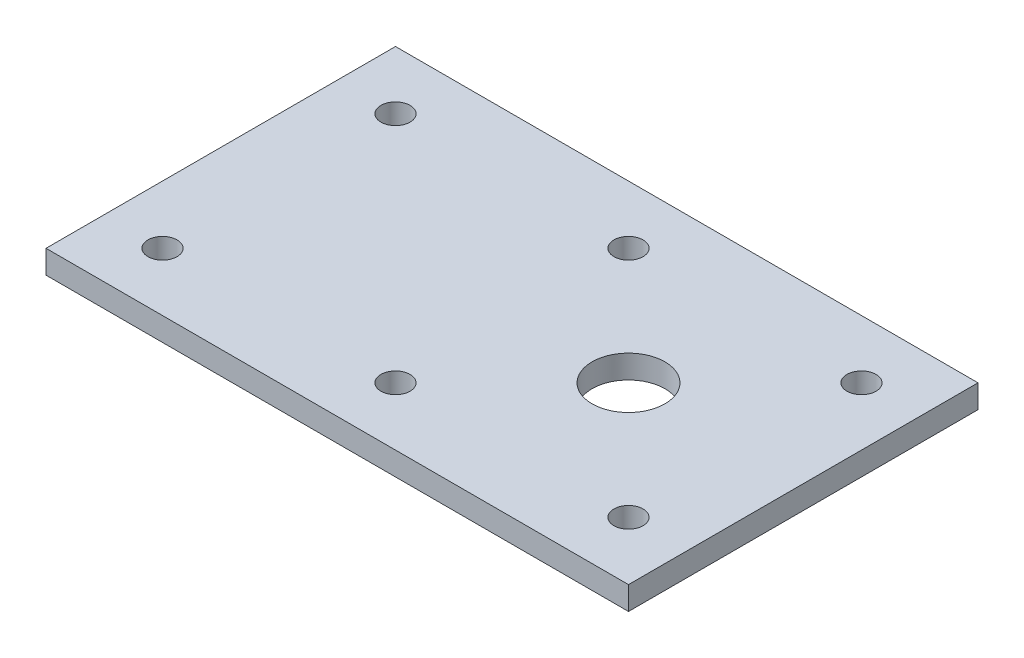
from build123d import *

# Parameters (mm, degrees)
SKETCH2_W            = 200
SKETCH2_H            = 120
BOSS_EXTRUDE1_DEPTH  = 8
SKETCH4_R            = 5
CUT_EXTRUDE1_DEPTH   = 8
LPATTERN2_COUNT      = 2
LPATTERN2_PITCH      = 80
LPATTERN2_COUNT_DIR2 = 3
LPATTERN2_PITCH_DIR2 = 80
SKETCH5_R            = 12.5
CUT_EXTRUDE2_DEPTH   = 50


with BuildPart() as part:
    # Sketch2 → Boss-Extrude1 (new body)
    with BuildSketch(Plane(origin=(0, 0, 0), x_dir=(1, 0, 0), z_dir=(0, 1, 0))):
        with Locations((9.640831758, -20.11342155)):
            Rectangle(SKETCH2_W, SKETCH2_H)
    extrude(amount=BOSS_EXTRUDE1_DEPTH)

    # Sketch4 → Cut-Extrude1 (cut)
    with BuildSketch(Plane(origin=(0, 8, 0), x_dir=(1, 0, 0), z_dir=(0, 1, 0))):
        with Locations((-70.359168242, 19.88657845)):
            Circle(SKETCH4_R)
    cut_extrude1 = extrude(amount=-CUT_EXTRUDE1_DEPTH, mode=Mode.SUBTRACT)

    # LPattern2: Cut-Extrude1 2 × 3
    with Locations(*[(j * LPATTERN2_PITCH_DIR2, 0, i * LPATTERN2_PITCH) for i in range(LPATTERN2_COUNT) for j in range(LPATTERN2_COUNT_DIR2) if (i, j) != (0, 0)]):
        add(cut_extrude1, mode=Mode.SUBTRACT)

    # Sketch5 → Cut-Extrude2 (cut)
    with BuildSketch(Plane.XZ):
        with Locations((49.640831758, 20.11342155)):
            Circle(SKETCH5_R)
    extrude(amount=-CUT_EXTRUDE2_DEPTH, mode=Mode.SUBTRACT)


solid = part.part
